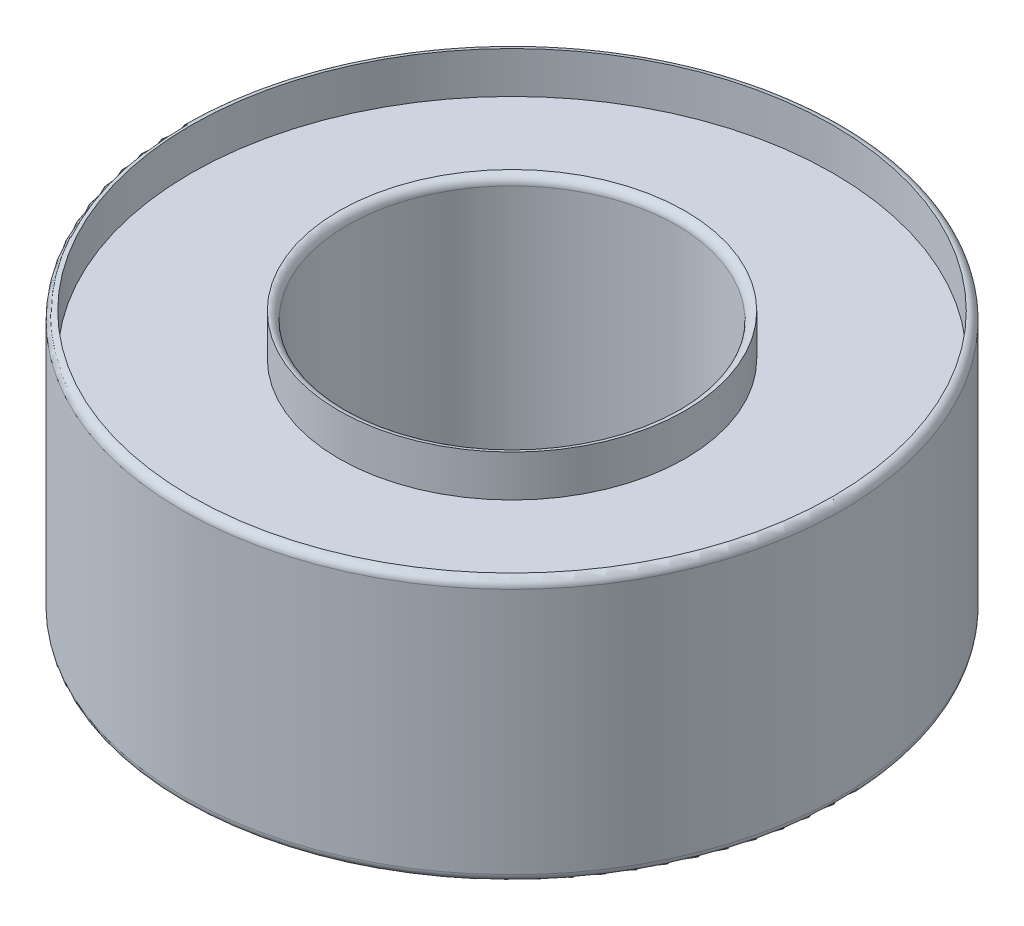
from build123d import *

# Parameters (mm, degrees)
SKETCH1_R           = 3.96875
SKETCH1_R_2         = 1.984375
BOSS_EXTRUDE1_DEPTH = 3.175
FILLET1_R           = 0.1
SKETCH2_R           = 3.86875
SKETCH2_R_2         = 2.084375
CUT_EXTRUDE1_DEPTH  = 0.5
SKETCH3_R           = 3.86875
SKETCH3_R_2         = 2.084375
CUT_EXTRUDE2_DEPTH  = 0.5


with BuildPart() as part:
    # Sketch1 → Boss-Extrude1 (new body)
    with BuildSketch(Plane(origin=(0, 0, 0), x_dir=(1, 0, 0), z_dir=(0, 1, 0))):
        Circle(SKETCH1_R)
        Circle(SKETCH1_R_2, mode=Mode.SUBTRACT)
    extrude(amount=BOSS_EXTRUDE1_DEPTH)

    # Fillet1
    fillet1_edges = [part.edges().sort_by_distance(p)[0] for p in [
        (-3.96875, 0, 0),
        (-3.96875, 3.175, 0),
        (-1.984375, 0, 0),
        (-1.984375, 3.175, 0),
    ]]
    fillet(fillet1_edges, radius=FILLET1_R)

    # Sketch2 → Cut-Extrude1 (cut)
    with BuildSketch(Plane(origin=(0, 3.175, 0), x_dir=(1, 0, 0), z_dir=(0, 1, 0))):
        Circle(SKETCH2_R)
        Circle(SKETCH2_R_2, mode=Mode.SUBTRACT)
    extrude(amount=-CUT_EXTRUDE1_DEPTH, mode=Mode.SUBTRACT)

    # Sketch3 → Cut-Extrude2 (cut)
    with BuildSketch(Plane.XZ):
        Circle(SKETCH3_R)
        Circle(SKETCH3_R_2, mode=Mode.SUBTRACT)
    extrude(amount=-CUT_EXTRUDE2_DEPTH, mode=Mode.SUBTRACT)


solid = part.part
